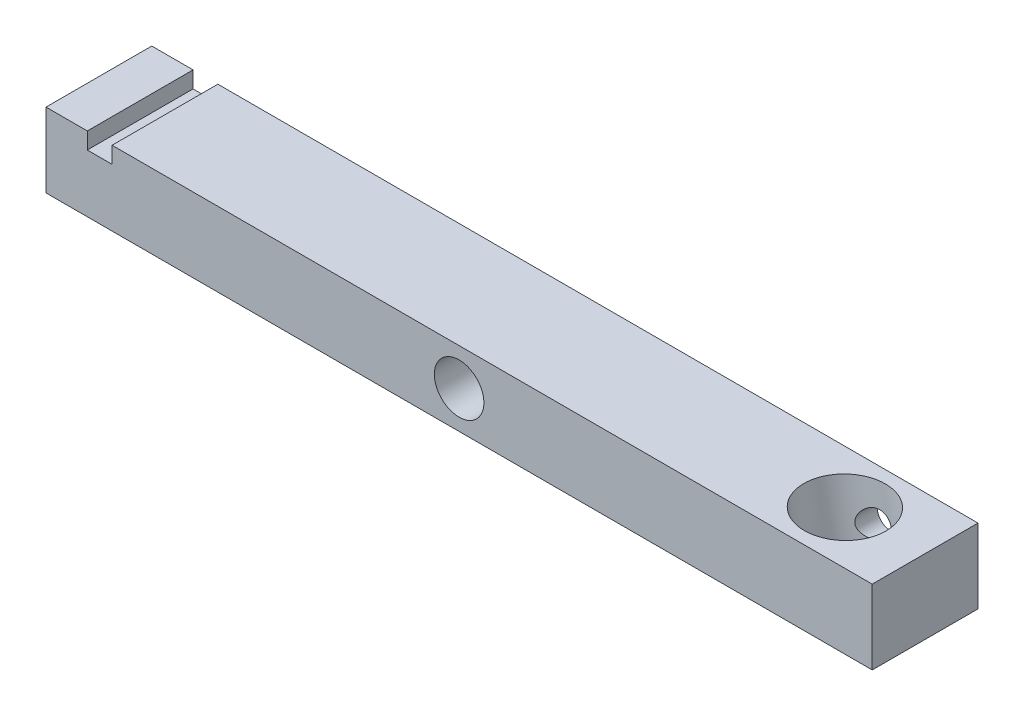
from build123d import *

# Parameters (mm, degrees)
SKETCH1_W           = 127
SKETCH1_H           = 11.43
BOSS_EXTRUDE1_DEPTH = 8.128
SKETCH6_W           = 3.81
SKETCH6_H           = 2.54
CUT_EXTRUDE1_DEPTH  = 16.256
SKETCH12_R          = 3.81
CUT_EXTRUDE2_DEPTH  = 16.256
SKETCH14_R          = 6.223
CUT_EXTRUDE3_DEPTH  = 25.4
CUT_EXTRUDE4_REACH  = 18.256
SKETCH17_R          = 2.032


with BuildPart() as part:
    # Sketch1 → Boss-Extrude1 (new body, symmetric)
    with BuildSketch(Plane.XY):
        Rectangle(SKETCH1_W, SKETCH1_H)
    extrude(amount=BOSS_EXTRUDE1_DEPTH, both=True)

    # Sketch6 → Cut-Extrude1 (cut)
    with BuildSketch(Plane.XY.offset(8.128)):
        with Locations((-55.245, 4.445)):
            Rectangle(SKETCH6_W, SKETCH6_H)
    extrude(amount=-CUT_EXTRUDE1_DEPTH, mode=Mode.SUBTRACT)

    # Sketch12 → Cut-Extrude2 (cut)
    with BuildSketch(Plane.XY.offset(8.128)):
        Circle(SKETCH12_R)
    extrude(amount=-CUT_EXTRUDE2_DEPTH, mode=Mode.SUBTRACT)

    # Sketch14 → Cut-Extrude3 (cut)
    with BuildSketch(Plane(origin=(2.89208185, -16.401811214, 0), x_dir=(0, 0, -1), z_dir=(0.173648178, -0.984807753, 0))):
        with Locations((0, 51.382892981)):
            Circle(SKETCH14_R)
    extrude(amount=-CUT_EXTRUDE3_DEPTH, mode=Mode.SUBTRACT)

    # Sketch17 → Cut-Extrude4 (cut, up to next)
    with BuildSketch(Plane(origin=(0, 0, -8.128), x_dir=(-1, 0, 0), z_dir=(0, 0, -1)), mode=Mode.PRIVATE) as cut_extrude4_sk1:
        with Locations((-50.048620668, 0)):
            Circle(SKETCH17_R)
    cut_extrude4_tool1 = extrude(cut_extrude4_sk1.sketch, amount=-CUT_EXTRUDE4_REACH, mode=Mode.PRIVATE) & part.part
    add(cut_extrude4_tool1.solids().sort_by_distance((50.048621, 0, -8.128))[0], mode=Mode.SUBTRACT)


solid = part.part
